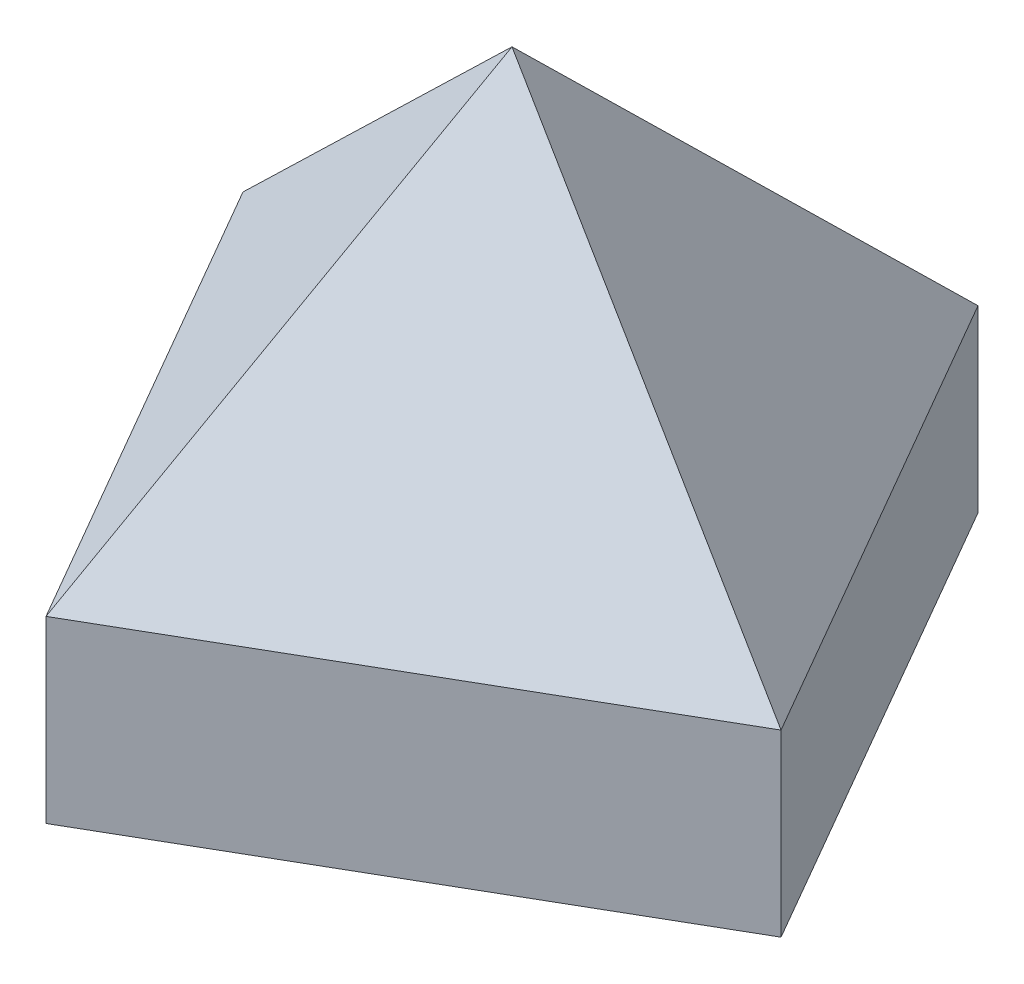
from build123d import *

# Parameters (mm, degrees)
EXTRUDE1_DEPTH = 75
EXTRUDE2_DEPTH = 108.475952642
EXTRUDE3_DEPTH = 108.475952642


with BuildPart() as part:
    # Sketch1 → Extrude1 (new body)
    with BuildSketch(Plane(origin=(0, 0, 0), x_dir=(1, 0, 0), z_dir=(0, 1, 0))):
        Polygon((-92.5, -15), (-55, -79.951905284), (-119.951905284, -117.451905284), (-157.451905284, -52.5), align=None)
    extrude(amount=EXTRUDE1_DEPTH)

    # Sketch2 → Extrude2 (cut, through all)
    with BuildSketch(Plane(origin=(20.870190528, 0, 36.148230359), x_dir=(0.866025404, 0, -0.5), z_dir=(0.5, 0, 0.866025404))):
        Polygon((-162.60734985, 25), (-125.10734985, 75), (-162.60734985, 75), align=None)
        Polygon((-87.60734985, 75), (-125.10734985, 75), (-87.60734985, 25), align=None)
    extrude(amount=-EXTRUDE2_DEPTH, mode=Mode.SUBTRACT)

    # Sketch3 → Extrude3 (cut, through all)
    with BuildSketch(Plane(origin=(-140.822095812, 0, 81.303674925), x_dir=(0.5, 0, 0.866025404), z_dir=(-0.866025404, 0, 0.5))):
        Polygon((-33.259618943, 75), (4.240381057, 75), (-33.259618943, 25), align=None)
        Polygon((41.740381057, 75), (41.740381057, 25), (4.240381057, 75), align=None)
    extrude(amount=-EXTRUDE3_DEPTH, mode=Mode.SUBTRACT)


solid = part.part
